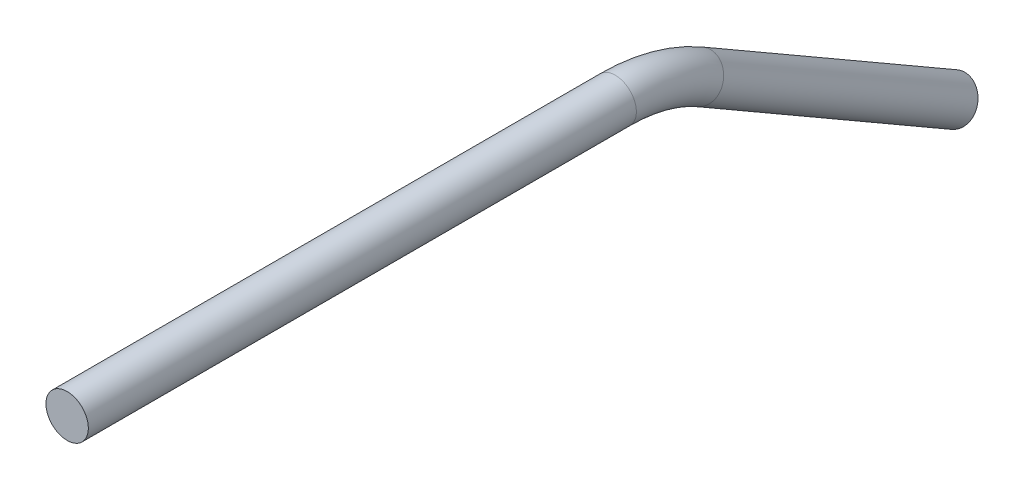
from build123d import *

# Parameters (mm, degrees)
SKETCH2_R = 3.175


with BuildPart() as part:
    # Sweep1: sweep along a path in Sketch4
    with BuildLine(Plane(origin=(0, 0, 0), x_dir=(0, 0, -1), z_dir=(1, 0, 0))) as sweep1_path:
        Line((0, 0), (82.094090512, 0))
        ThreePointArc((82.094090512, 0), (88.668094258, -0.865484012), (94.794090512, -3.402954744))
        Line((94.794090512, -3.402954744), (132.894090512, -25.4))
    # Sketch2 → Sweep1 (sweep)
    with BuildSketch(Plane.XY):
        Circle(SKETCH2_R)
    sweep(path=sweep1_path.line)


solid = part.part
